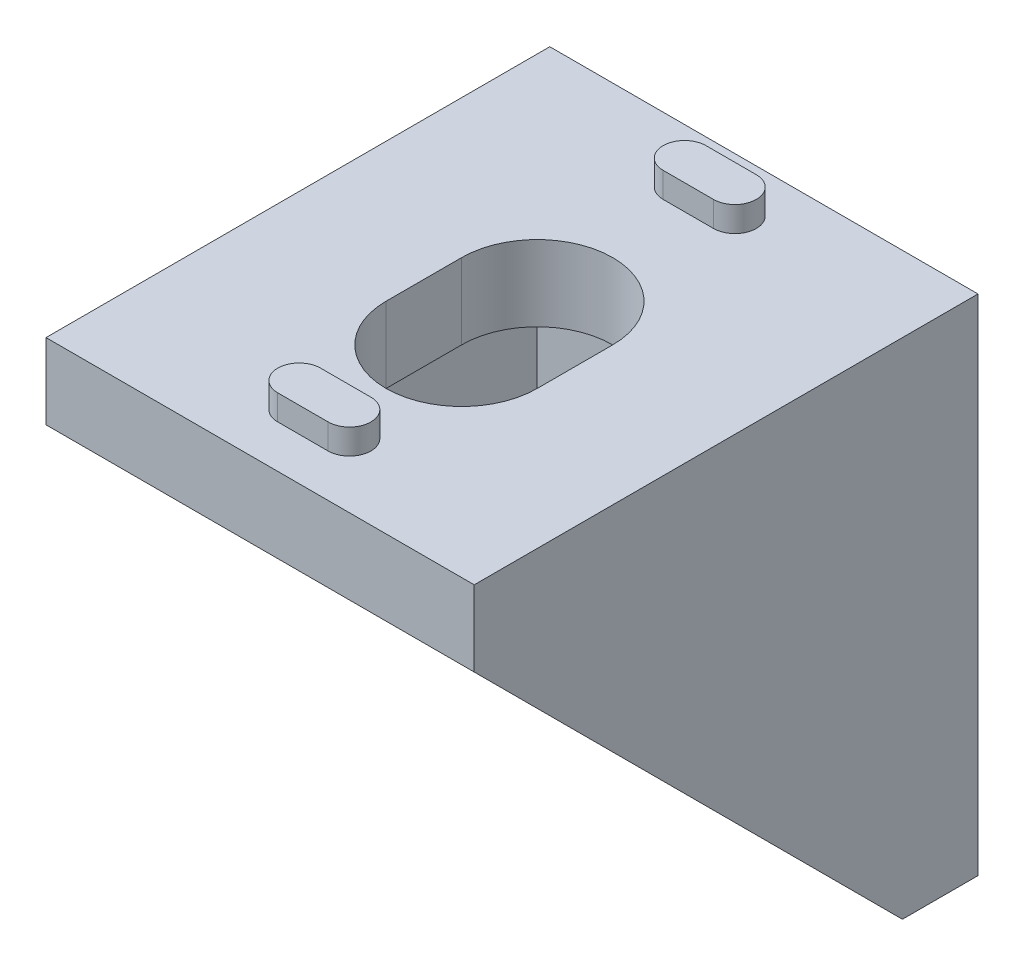
from build123d import *

# Parameters (mm, degrees)
BOSS_EXTRUDE1_DEPTH = 8.5
SKETCH2_W           = 17
SKETCH2_H           = 17
CUT_EXTRUDE1_DEPTH  = 6
CUT_EXTRUDE2_DEPTH  = 3
BOSS_EXTRUDE2_DEPTH = 1


with BuildPart() as part:
    # Sketch1 → Boss-Extrude1 (new body, symmetric)
    with BuildSketch(Plane(origin=(0, 0, 0), x_dir=(0, 0, -1), z_dir=(1, 0, 0))):
        Polygon((0, 0), (-20, 0), (-20, -3), (-11.5, -11.5), (-3, -20), (0, -20), align=None)
    extrude(amount=BOSS_EXTRUDE1_DEPTH, both=True)

    # Sketch2 → Cut-Extrude1 (cut, symmetric)
    with BuildSketch(Plane(origin=(0, 0, 0), x_dir=(0, 0, -1), z_dir=(1, 0, 0))):
        with Locations((-11.5, -11.5)):
            Rectangle(SKETCH2_W, SKETCH2_H)
    extrude(amount=CUT_EXTRUDE1_DEPTH, both=True, mode=Mode.SUBTRACT)

    # Sketch3 → Cut-Extrude2 (cut)
    with BuildSketch(Plane.XY.offset(3)):
        with BuildLine():
            Line((-3, -9), (-3, -12))
            ThreePointArc((-3, -12), (0, -15), (3, -12))
            Line((3, -12), (3, -9))
            ThreePointArc((3, -9), (0, -6), (-3, -9))
        make_face()
    cut_extrude2 = extrude(amount=-CUT_EXTRUDE2_DEPTH, mode=Mode.SUBTRACT)

    # Sketch4 → Boss-Extrude2 (add)
    with BuildSketch(Plane(origin=(0, 0, 0), x_dir=(-1, 0, 0), z_dir=(0, 0, -1))):
        with BuildLine():
            Line((-1, -3), (1, -3))
            ThreePointArc((1, -3), (1.85, -2.15), (1, -1.3))
            Line((1, -1.3), (-1, -1.3))
            ThreePointArc((-1, -1.3), (-1.85, -2.15), (-1, -3))
        make_face()
        with BuildLine():
            Line((-1, -18.3), (1, -18.3))
            ThreePointArc((1, -18.3), (1.85, -17.45), (1, -16.6))
            Line((1, -16.6), (-1, -16.6))
            ThreePointArc((-1, -16.6), (-1.85, -17.45), (-1, -18.3))
        make_face()
    boss_extrude2 = extrude(amount=BOSS_EXTRUDE2_DEPTH)

    # Mirror1: Cut-Extrude2, Boss-Extrude2 across plane
    add(cut_extrude2.mirror(Plane(origin=(0, 0, 0), x_dir=(0, -0.707106781, 0.707106781), z_dir=(0, 0.707106781, 0.707106781))), mode=Mode.SUBTRACT)
    add(boss_extrude2.mirror(Plane(origin=(0, 0, 0), x_dir=(0, -0.707106781, 0.707106781), z_dir=(0, 0.707106781, 0.707106781))))


solid = part.part
